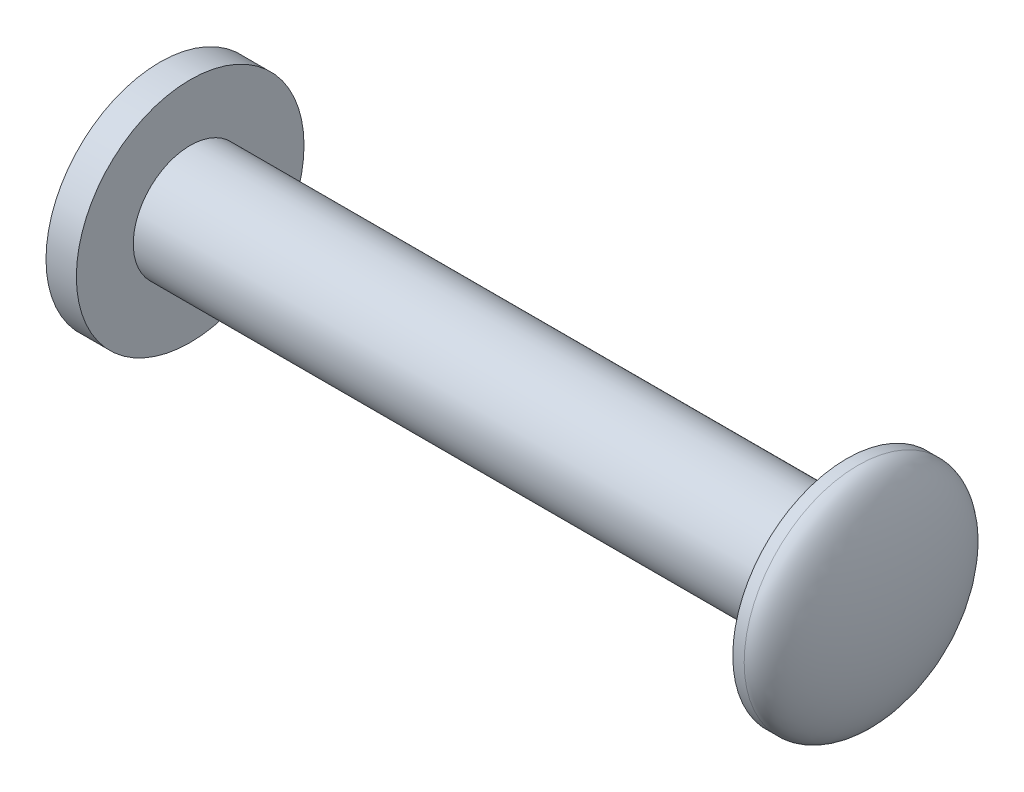
from build123d import *

# Parameters (mm, degrees)
CROQUIS1_R              = 3
SALIENTE_EXTRUIR1_DEPTH = 0.8
CROQUIS2_R              = 1.5
SALIENTE_EXTRUIR2_DEPTH = 17.3
CROQUIS3_R              = 3
SALIENTE_EXTRUIR3_DEPTH = 0.3
C_PULA1_FACE_RADIUS     = 3
C_PULA1_HEIGHT          = 1


with BuildPart() as part:
    # Croquis1 → Saliente-Extruir1 (new body)
    with BuildSketch(Plane(origin=(0, 0, 0), x_dir=(0, 0, -1), z_dir=(1, 0, 0))):
        Circle(CROQUIS1_R)
    extrude(amount=SALIENTE_EXTRUIR1_DEPTH)

    # Croquis2 → Saliente-Extruir2 (add)
    with BuildSketch(Plane(origin=(0.8, 0, 0), x_dir=(0, 0, -1), z_dir=(1, 0, 0))):
        Circle(CROQUIS2_R)
    extrude(amount=SALIENTE_EXTRUIR2_DEPTH)

    # Croquis3 → Saliente-Extruir3 (add)
    with BuildSketch(Plane(origin=(18.1, 0, 0), x_dir=(0, 0, -1), z_dir=(1, 0, 0))):
        Circle(CROQUIS3_R)
    extrude(amount=SALIENTE_EXTRUIR3_DEPTH)

    # Cúpula1: an elliptical dome of height H over a round flat face of radius A is half a spheroid: the quarter ellipse of half axes A and H revolved about the face's axis
    with BuildSketch(Plane((18.4, 0, 0), x_dir=(0, 0, 1), z_dir=(0, 1, 0)), mode=Mode.PRIVATE) as c_pula1_quarter:
        Ellipse(C_PULA1_FACE_RADIUS, C_PULA1_HEIGHT)
        Rectangle(C_PULA1_FACE_RADIUS, C_PULA1_HEIGHT, align=(Align.MIN, Align.MIN), mode=Mode.INTERSECT)
    revolve(c_pula1_quarter.sketch, axis=Axis((18.4, 0, 0), (1, 0, 0)))


solid = part.part
